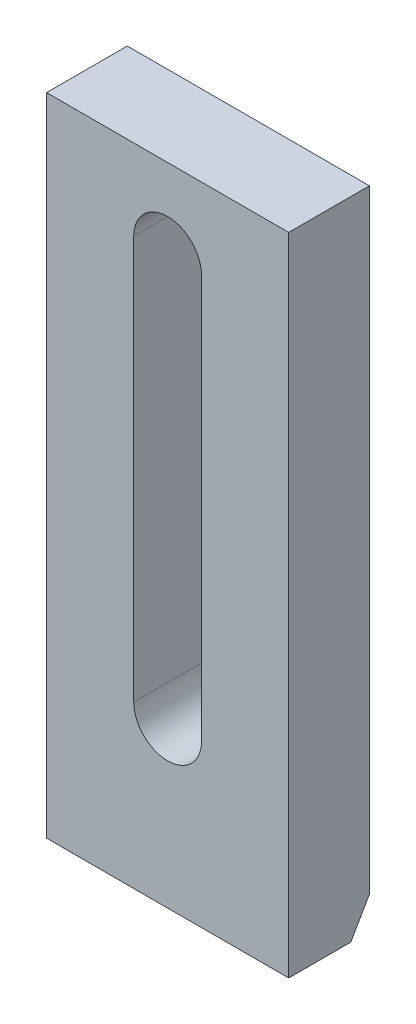
from build123d import *

# Parameters (mm, degrees)
SKETCH_1_W          = 75
SKETCH_1_H          = 200
EXTRUDE_1_DEPTH     = 25
CUT_EXTRUDE_1_DEPTH = 26
CHAMFER_1_SIZE      = 10
CHAMFER_1_SIZE2     = 5.773502692


with BuildPart() as part:
    # Эскиз1 → Бобышка-Вытянуть1 (new body)
    with BuildSketch(Plane.XY):
        with Locations((37.5, 100)):
            Rectangle(SKETCH_1_W, SKETCH_1_H)
    extrude(amount=EXTRUDE_1_DEPTH)

    # Эскиз2 → Вырез-Вытянуть1 (cut, through all)
    with BuildSketch(Plane.XY.offset(25)):
        with BuildLine():
            Line((27, 50), (27, 175))
            ThreePointArc((27, 175), (37.5, 185.5), (48, 175))
            Line((48, 175), (48, 50))
            ThreePointArc((48, 50), (37.5, 39.5), (27, 50))
        make_face()
    extrude(amount=-CUT_EXTRUDE_1_DEPTH, mode=Mode.SUBTRACT)

    # Фаска1
    chamfer_1_edges = [part.edges().sort_by_distance(p)[0] for p in [
        (37.5, 0, 0),
    ]]
    chamfer_1_side = [part.faces().sort_by_distance(p)[0] for p in [
        (37.5, 2.136000936, 0),
    ]]
    chamfer(chamfer_1_edges, length=CHAMFER_1_SIZE, length2=CHAMFER_1_SIZE2, reference=chamfer_1_side[0])


solid = part.part
